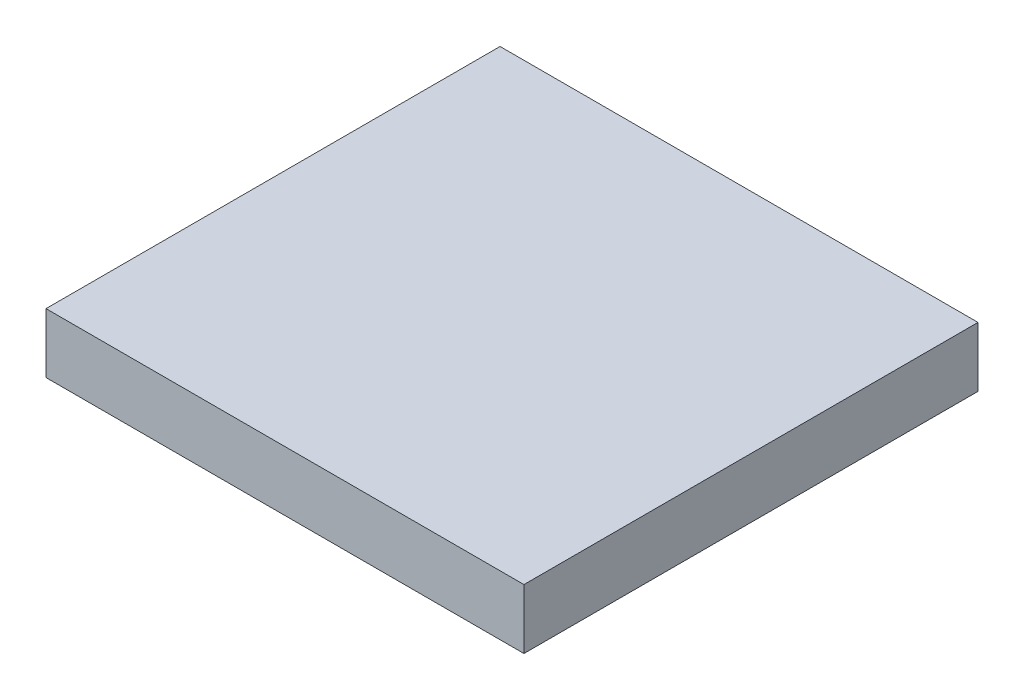
from build123d import *

# Parameters (mm, degrees)
SKETCH1_W       = 12.7
SKETCH1_H       = 12.065
LOWERBASE_DEPTH = 1.5875


with BuildPart() as part:
    # Sketch1 → LowerBase (new body)
    with BuildSketch(Plane(origin=(0, 0, 0), x_dir=(1, 0, 0), z_dir=(0, 1, 0))):
        with Locations((0, -0.3175)):
            Rectangle(SKETCH1_W, SKETCH1_H)
    extrude(amount=LOWERBASE_DEPTH)


solid = part.part
